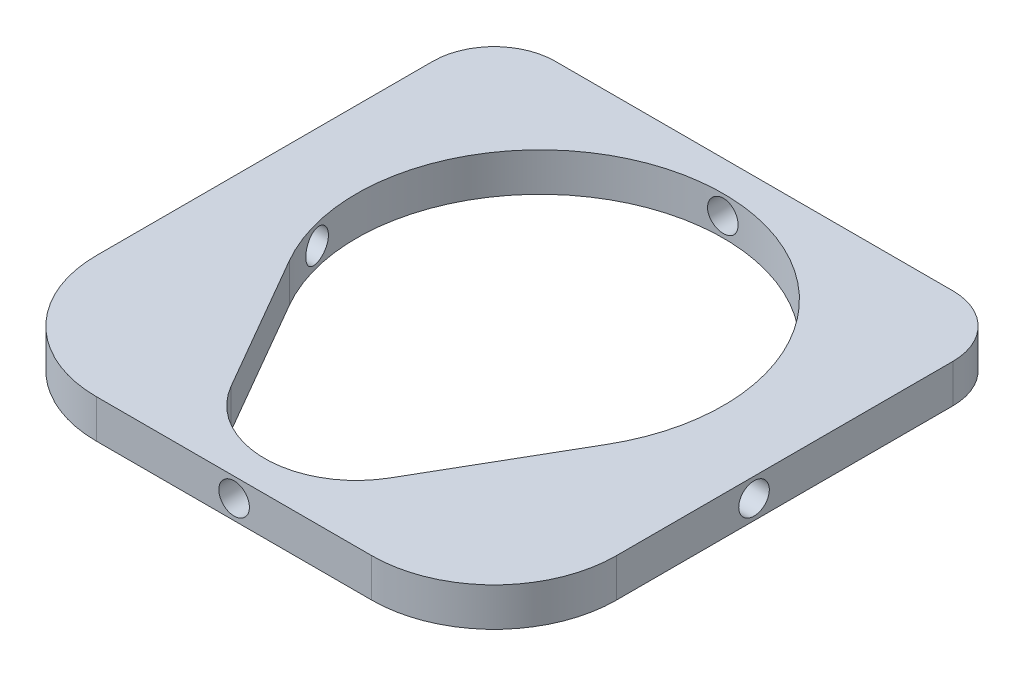
from build123d import *

# Parameters (mm, degrees)
SKETCH1_W           = 85
SKETCH1_H           = 85
BOSS_EXTRUDE1_DEPTH = 6.3
CUT_EXTRUDE1_DEPTH  = 10
SKETCH3_R           = 2.5
CUT_EXTRUDE2_DEPTH  = 86
SKETCH4_R           = 2.5
CUT_EXTRUDE3_DEPTH  = 86
FILLET1_R           = 20
FILLET2_R           = 10


with BuildPart() as part:
    # Sketch1 → Boss-Extrude1 (new body)
    with BuildSketch(Plane(origin=(0, 0, 0), x_dir=(1, 0, 0), z_dir=(0, 1, 0))):
        with Locations((42.5, 42.5)):
            Rectangle(SKETCH1_W, SKETCH1_H)
    extrude(amount=BOSS_EXTRUDE1_DEPTH)

    # Sketch2 → Cut-Extrude1 (cut)
    with BuildSketch(Plane(origin=(0, 6.3, 0), x_dir=(1, 0, 0), z_dir=(0, 1, 0))):
        with BuildLine():
            Line((16.519237886, 35), (29.509618943, 12.5))
            ThreePointArc((29.509618943, 12.5), (42.5, 5), (55.490381057, 12.5))
            Line((55.490381057, 12.5), (68.480762114, 35))
            ThreePointArc((68.480762114, 35), (42.5, 80), (16.519237886, 35))
        make_face()
    extrude(amount=-CUT_EXTRUDE1_DEPTH, mode=Mode.SUBTRACT)

    # Sketch3 → Cut-Extrude2 (cut, through all)
    with BuildSketch(Plane.XY):
        with Locations((42.5, 3.15)):
            Circle(SKETCH3_R)
    extrude(amount=-CUT_EXTRUDE2_DEPTH, mode=Mode.SUBTRACT)

    # Sketch4 → Cut-Extrude3 (cut, through all)
    with BuildSketch(Plane.ZY):
        with Locations((-42.5, 3.15)):
            Circle(SKETCH4_R)
    extrude(amount=-CUT_EXTRUDE3_DEPTH, mode=Mode.SUBTRACT)

    # Fillet1
    fillet1_edges = [part.edges().sort_by_distance(p)[0] for p in [
        (85, 3.15, 0),
        (0, 3.15, 0),
    ]]
    fillet(fillet1_edges, radius=FILLET1_R)

    # Fillet2
    fillet2_edges = [part.edges().sort_by_distance(p)[0] for p in [
        (0, 3.15, -85),
        (85, 3.15, -85),
    ]]
    fillet(fillet2_edges, radius=FILLET2_R)


solid = part.part
